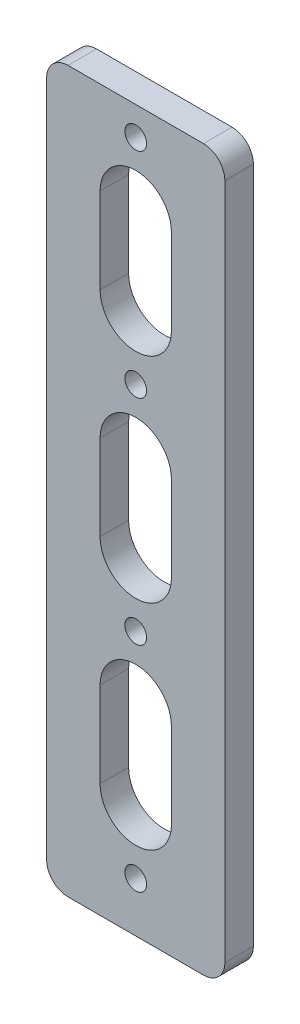
from build123d import *

# Parameters (mm, degrees)
SKETCH_1_W               = 25
SKETCH_1_H               = 101
EXTRUDE_1_DEPTH          = 4
SKETCH_3_R               = 1.525
CUT_EXTRUDE_1_DEPTH      = 1
CUT_EXTRUDE_1_DEPTH_BACK = 5
FILLET_1_R               = 3
CUT_EXTRUDE_2_DEPTH      = 1
CUT_EXTRUDE_2_DEPTH_BACK = 5


with BuildPart() as part:
    # 草图1 → 凸台-拉伸1 (new body)
    with BuildSketch(Plane.XY):
        Rectangle(SKETCH_1_W, SKETCH_1_H)
    extrude(amount=EXTRUDE_1_DEPTH)

    # 草图3 → 切除-拉伸1 (cut, two sides)
    with BuildSketch(Plane(origin=(0, 0, 0), x_dir=(-1, 0, 0), z_dir=(0, 0, -1))) as cut_extrude_1_sk:
        with Locations((0, -43.500000001)):
            Circle(SKETCH_3_R)
        with Locations((0, -13.500000001)):
            Circle(SKETCH_3_R)
        with Locations((0, 16.499999999)):
            Circle(SKETCH_3_R)
        with Locations((0, 46.499999999)):
            Circle(SKETCH_3_R)
    extrude(amount=CUT_EXTRUDE_1_DEPTH, mode=Mode.SUBTRACT)
    extrude(cut_extrude_1_sk.sketch, amount=-CUT_EXTRUDE_1_DEPTH_BACK, mode=Mode.SUBTRACT)

    # 圆角1
    fillet_1_edges = [part.edges().sort_by_distance(p)[0] for p in [
        (12.5, -50.5, 2),
        (-12.5, -50.5, 2),
        (-12.5, 50.5, 2),
        (12.5, 50.5, 2),
    ]]
    fillet(fillet_1_edges, radius=FILLET_1_R)

    # 草图4 → 切除-拉伸2 (cut, two sides)
    with BuildSketch(Plane.XY.offset(4)) as cut_extrude_2_sk:
        with BuildLine():
            Line((-5, -34.500000001), (-5, -22.500000001))
            ThreePointArc((-5, -22.500000001), (0, -17.500000001), (5, -22.500000001))
            Line((5, -22.500000001), (5, -34.500000001))
            ThreePointArc((5, -34.500000001), (0, -39.500000001), (-5, -34.500000001))
        make_face()
        with BuildLine():
            Line((-5, -4.500000001), (-5, 7.499999999))
            ThreePointArc((-5, 7.499999999), (0, 12.499999999), (5, 7.499999999))
            Line((5, 7.499999999), (5, -4.500000001))
            ThreePointArc((5, -4.500000001), (0, -9.500000001), (-5, -4.500000001))
        make_face()
        with BuildLine():
            Line((-5, 25.499999999), (-5, 37.499999999))
            ThreePointArc((-5, 37.499999999), (0, 42.499999999), (5, 37.499999999))
            Line((5, 37.499999999), (5, 25.499999999))
            ThreePointArc((5, 25.499999999), (0, 20.499999999), (-5, 25.499999999))
        make_face()
    extrude(amount=CUT_EXTRUDE_2_DEPTH, mode=Mode.SUBTRACT)
    extrude(cut_extrude_2_sk.sketch, amount=-CUT_EXTRUDE_2_DEPTH_BACK, mode=Mode.SUBTRACT)


solid = part.part
